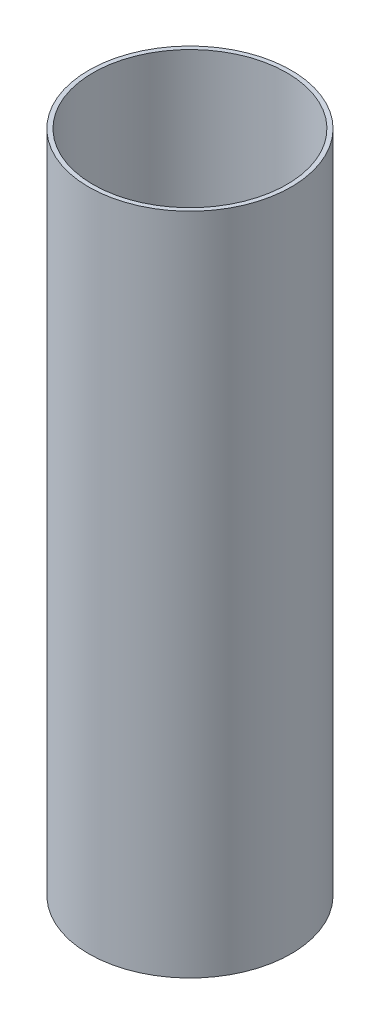
from build123d import *

# Parameters (mm, degrees)
SKETCH1_R           = 76.2
SKETCH1_R_2         = 72.95
BOSS_EXTRUDE1_DEPTH = 500


with BuildPart() as part:
    # Sketch1 → Boss-Extrude1 (new body)
    with BuildSketch(Plane(origin=(0, 0, 0), x_dir=(1, 0, 0), z_dir=(0, 1, 0))):
        Circle(SKETCH1_R)
        Circle(SKETCH1_R_2, mode=Mode.SUBTRACT)
    extrude(amount=BOSS_EXTRUDE1_DEPTH)


solid = part.part
